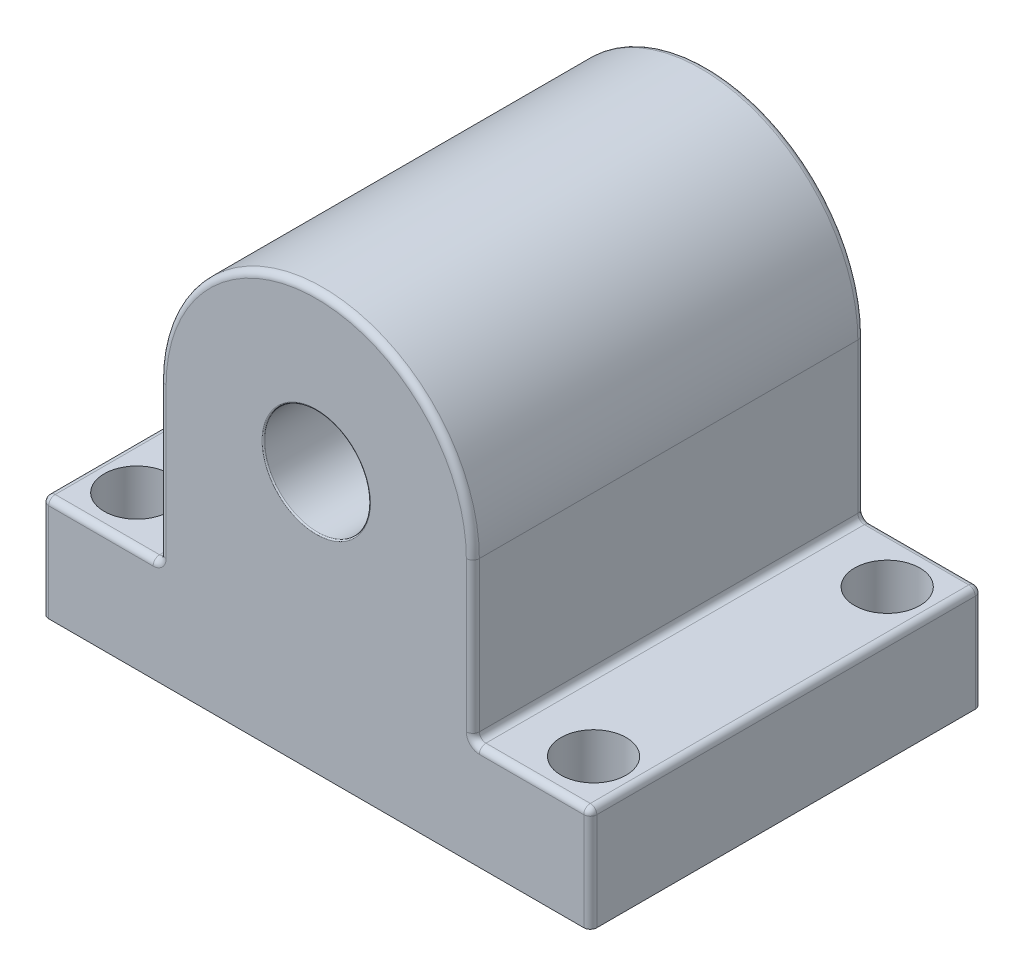
from build123d import *

# Parameters (mm, degrees)
CROQUIS1_R              = 4.05
SALIENTE_EXTRUIR1_DEPTH = 15
CORTAR_EXTRUIR1_REACH   = 10
CROQUIS2_R              = 2.5
REDONDEO1_R             = 0.5
REDONDEO2_R             = 0.1


with BuildPart() as part:
    # Croquis1 → Saliente-Extruir1 (new body, symmetric)
    with BuildSketch(Plane.XY):
        with BuildLine():
            Line((21, 0), (-21, 0))
            Line((-21, 0), (-21, 8))
            Line((-21, 8), (-12, 8))
            Line((-12, 8), (-12, 20))
            ThreePointArc((-12, 20), (0, 32), (12, 20))
            Line((12, 20), (12, 8))
            Line((12, 8), (21, 8))
            Line((21, 8), (21, 0))
        make_face()
        with Locations((0, 20)):
            Circle(CROQUIS1_R, mode=Mode.SUBTRACT)
    extrude(amount=SALIENTE_EXTRUIR1_DEPTH, both=True)

    # Croquis2 → Cortar-Extruir1 (cut, up to next)
    with BuildSketch(Plane(origin=(0, 8, 0), x_dir=(1, 0, 0), z_dir=(0, 1, 0)), mode=Mode.PRIVATE) as cortar_extruir1_sk1:
        with Locations((-17.5, 11.25)):
            Circle(CROQUIS2_R)
    cortar_extruir1_tool1 = extrude(cortar_extruir1_sk1.sketch, amount=-CORTAR_EXTRUIR1_REACH, mode=Mode.PRIVATE) & part.part
    add(cortar_extruir1_tool1.solids().sort_by_distance((-17.5, 8, -11.25))[0], mode=Mode.SUBTRACT)
    # Croquis2 → Cortar-Extruir1 (cut, up to next)
    with BuildSketch(Plane(origin=(0, 8, 0), x_dir=(1, 0, 0), z_dir=(0, 1, 0)), mode=Mode.PRIVATE) as cortar_extruir1_sk2:
        with Locations((17.5, 11.25)):
            Circle(CROQUIS2_R)
    cortar_extruir1_tool2 = extrude(cortar_extruir1_sk2.sketch, amount=-CORTAR_EXTRUIR1_REACH, mode=Mode.PRIVATE) & part.part
    add(cortar_extruir1_tool2.solids().sort_by_distance((17.5, 8, -11.25))[0], mode=Mode.SUBTRACT)
    # Croquis2 → Cortar-Extruir1 (cut, up to next)
    with BuildSketch(Plane(origin=(0, 8, 0), x_dir=(1, 0, 0), z_dir=(0, 1, 0)), mode=Mode.PRIVATE) as cortar_extruir1_sk3:
        with Locations((-17.5, -11.25)):
            Circle(CROQUIS2_R)
    cortar_extruir1_tool3 = extrude(cortar_extruir1_sk3.sketch, amount=-CORTAR_EXTRUIR1_REACH, mode=Mode.PRIVATE) & part.part
    add(cortar_extruir1_tool3.solids().sort_by_distance((-17.5, 8, 11.25))[0], mode=Mode.SUBTRACT)
    # Croquis2 → Cortar-Extruir1 (cut, up to next)
    with BuildSketch(Plane(origin=(0, 8, 0), x_dir=(1, 0, 0), z_dir=(0, 1, 0)), mode=Mode.PRIVATE) as cortar_extruir1_sk4:
        with Locations((17.5, -11.25)):
            Circle(CROQUIS2_R)
    cortar_extruir1_tool4 = extrude(cortar_extruir1_sk4.sketch, amount=-CORTAR_EXTRUIR1_REACH, mode=Mode.PRIVATE) & part.part
    add(cortar_extruir1_tool4.solids().sort_by_distance((17.5, 8, 11.25))[0], mode=Mode.SUBTRACT)

    # Redondeo1
    redondeo1_edges = [part.edges().sort_by_distance(p)[0] for p in [
        (12, 14, -15),
        (16.5, 8, 15),
        (21, 4, 15),
        (-21, 4, 15),
        (-16.5, 8, 15),
        (-12, 14, 15),
        (0, 32, 15),
        (12, 14, 15),
        (0, 32, -15),
        (12, 8, 0),
        (21, 8, 0),
        (-21, 8, 0),
        (-12, 8, 0),
        (-12, 14, -15),
        (-16.5, 8, -15),
        (-21, 4, -15),
        (21, 4, -15),
        (16.5, 8, -15),
    ]]
    fillet(redondeo1_edges, radius=REDONDEO1_R)

    # Redondeo2
    redondeo2_edges = [part.edges().sort_by_distance(p)[0] for p in [
        (-4.05, 20, 15),
        (-4.05, 20, -15),
    ]]
    fillet(redondeo2_edges, radius=REDONDEO2_R)


solid = part.part
